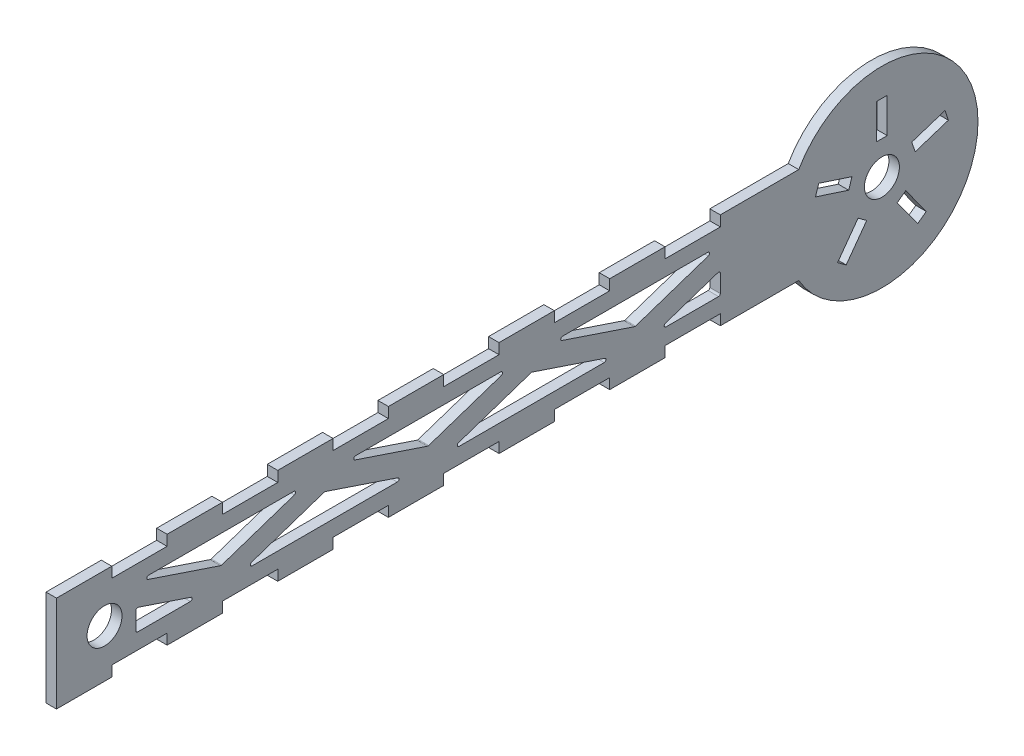
from build123d import *

# Parameters (mm, degrees)
SKETCH1_W           = 3.05
SKETCH1_H           = 10
SKETCH1_R           = 5
BOSS_EXTRUDE1_DEPTH = 3
CUT_EXTRUDE1_DEPTH  = 3
FILLET1_R           = 0.5


with BuildPart() as part:
    # Sketch1 → Boss-Extrude1 (new body)
    with BuildSketch(Plane(origin=(0, 0, 0), x_dir=(0, 0, -1), z_dir=(1, 0, 0))):
        with BuildLine():
            Line((-125, 13.75), (-125, -13.75))
            Line((-125, -13.75), (-109.166666667, -13.75))
            Line((-109.166666667, -13.75), (-109.166666667, -10.75))
            Line((-109.166666667, -10.75), (-93.333333333, -10.75))
            Line((-93.333333333, -10.75), (-93.333333333, -13.75))
            Line((-93.333333333, -13.75), (-77.5, -13.75))
            Line((-77.5, -13.75), (-77.5, -10.75))
            Line((-77.5, -10.75), (-61.666666667, -10.75))
            Line((-61.666666667, -10.75), (-61.666666667, -13.75))
            Line((-61.666666667, -13.75), (-45.833333333, -13.75))
            Line((-45.833333333, -13.75), (-45.833333333, -10.75))
            Line((-45.833333333, -10.75), (-30, -10.75))
            Line((-30, -10.75), (-30, -13.75))
            Line((-30, -13.75), (-14.166666667, -13.75))
            Line((-14.166666667, -13.75), (-14.166666667, -10.75))
            Line((-14.166666667, -10.75), (1.666666667, -10.75))
            Line((1.666666667, -10.75), (1.666666667, -13.75))
            Line((1.666666667, -13.75), (17.5, -13.75))
            Line((17.5, -13.75), (17.5, -10.75))
            Line((17.5, -10.75), (33.333333333, -10.75))
            Line((33.333333333, -10.75), (33.333333333, -13.75))
            Line((33.333333333, -13.75), (49.166666667, -13.75))
            Line((49.166666667, -13.75), (49.166666667, -10.75))
            Line((49.166666667, -10.75), (65, -10.75))
            Line((65, -10.75), (65, -13.75))
            Line((65, -13.75), (87.434301396, -13.75))
            ThreePointArc((87.434301396, -13.75), (138.75, 0), (87.434301396, 13.75))
            Line((87.434301396, 13.75), (65, 13.75))
            Line((65, 13.75), (65, 10.75))
            Line((65, 10.75), (49.166666667, 10.75))
            Line((49.166666667, 10.75), (49.166666667, 13.75))
            Line((49.166666667, 13.75), (33.333333333, 13.75))
            Line((33.333333333, 13.75), (33.333333333, 10.75))
            Line((33.333333333, 10.75), (17.5, 10.75))
            Line((17.5, 10.75), (17.5, 13.75))
            Line((17.5, 13.75), (1.666666667, 13.75))
            Line((1.666666667, 13.75), (1.666666667, 10.75))
            Line((1.666666667, 10.75), (-14.166666667, 10.75))
            Line((-14.166666667, 10.75), (-14.166666667, 13.75))
            Line((-14.166666667, 13.75), (-30, 13.75))
            Line((-30, 13.75), (-30, 10.75))
            Line((-30, 10.75), (-45.833333333, 10.75))
            Line((-45.833333333, 10.75), (-45.833333333, 13.75))
            Line((-45.833333333, 13.75), (-61.666666667, 13.75))
            Line((-61.666666667, 13.75), (-61.666666667, 10.75))
            Line((-61.666666667, 10.75), (-77.5, 10.75))
            Line((-77.5, 10.75), (-77.5, 13.75))
            Line((-77.5, 13.75), (-93.333333333, 13.75))
            Line((-93.333333333, 13.75), (-93.333333333, 10.75))
            Line((-93.333333333, 10.75), (-109.166666667, 10.75))
            Line((-109.166666667, 10.75), (-109.166666667, 13.75))
            Line((-109.166666667, 13.75), (-125, 13.75))
        make_face()
        Polygon((104.432289187, -6.789288937), (106.89979102, -8.582033956), (101.021938497, -16.6722039), (98.554436664, -14.879458881), align=None, mode=Mode.SUBTRACT)
        Polygon((115.60020898, -8.582033956), (118.067710813, -6.789288937), (123.945563336, -14.879458881), (121.478061503, -16.6722039), align=None, mode=Mode.SUBTRACT)
        Polygon((120.756287821, 1.485300259), (119.813785988, 4.386022634), (129.324351151, 7.476192578), (130.266852984, 4.575470203), align=None, mode=Mode.SUBTRACT)
        with Locations((111.25, 14.5)):
            Rectangle(SKETCH1_W, SKETCH1_H, mode=Mode.SUBTRACT)
        with Locations((-111.25, 0)):
            Circle(SKETCH1_R, mode=Mode.SUBTRACT)
        with Locations((111.25, 0)):
            Circle(SKETCH1_R, mode=Mode.SUBTRACT)
        Polygon((102.686214012, 4.386022634), (101.743712179, 1.485300259), (92.233147016, 4.575470203), (93.175648849, 7.476192578), align=None, mode=Mode.SUBTRACT)
    extrude(amount=BOSS_EXTRUDE1_DEPTH)

    # Sketch3 → Cut-Extrude1 (cut)
    with BuildSketch(Plane(origin=(3, 0, 0), x_dir=(0, 0, -1), z_dir=(1, 0, 0))):
        Polygon((-102.25, 0), (-102.25, -6.25), (-83.618433679, -6.25), align=None)
        Polygon((-54.004487489, 6.25), (-101.701297271, 6.25), (-77.85289238, -1.75), align=None)
        Polygon((-48.23894619, 1.75), (-72.087351081, -6.25), (-24.390541299, -6.25), align=None)
        Polygon((5.223404891, 6.25), (-42.473404891, 6.25), (-18.625, -1.75), align=None)
        Polygon((10.98894619, 1.75), (-12.859458701, -6.25), (34.837351081, -6.25), align=None)
        Polygon((64.451297271, 6.25), (16.754487489, 6.25), (40.60289238, -1.75), align=None)
        Polygon((65, 0), (46.368433679, -6.25), (65, -6.25), align=None)
    extrude(amount=-CUT_EXTRUDE1_DEPTH, mode=Mode.SUBTRACT)

    # Fillet1
    fillet1_edges = [part.edges().sort_by_distance(p)[0] for p in [
        (1.5, -1.75, 18.625),
        (1.5, 6.25, 42.473404891),
        (1.5, 6.25, -5.223404891),
        (1.5, 1.75, -10.98894619),
        (1.5, -6.25, -34.837351081),
        (1.5, -6.25, 12.859458701),
        (1.5, -1.75, 77.85289238),
        (1.5, 6.25, 101.701297271),
        (1.5, 6.25, 54.004487489),
        (1.5, 1.75, 48.23894619),
        (1.5, -6.25, 24.390541299),
        (1.5, -6.25, 72.087351081),
        (1.5, -6.25, -46.368433679),
        (1.5, 0, -65),
        (1.5, -6.25, -65),
        (1.5, -1.75, -40.60289238),
        (1.5, 6.25, -16.754487489),
        (1.5, 6.25, -64.451297271),
        (1.5, 0, 102.25),
        (1.5, -6.25, 83.618433679),
        (1.5, -6.25, 102.25),
    ]]
    fillet(fillet1_edges, radius=FILLET1_R)


solid = part.part
